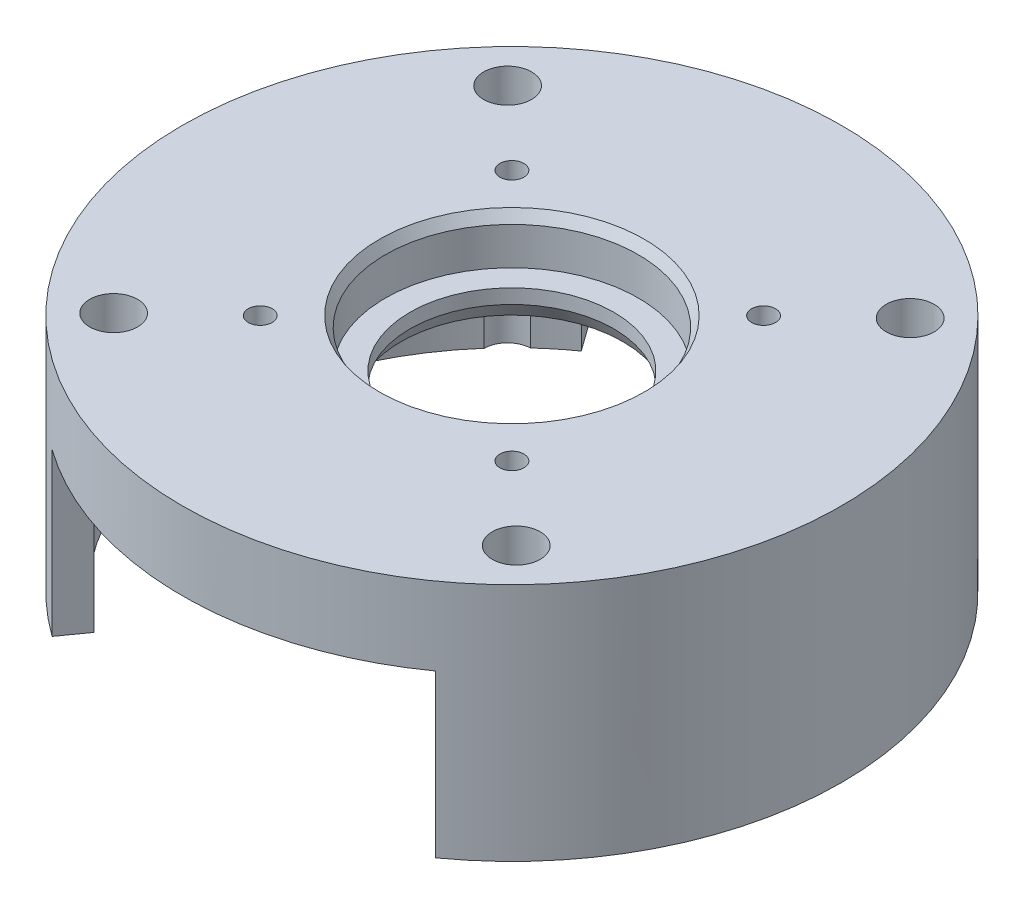
from build123d import *

# Parameters (mm, degrees)
SKETCH_1_R          = 55
EXTRUDE_1_DEPTH     = 40
SKETCH_2_R          = 50
CUT_EXTRUDE_1_DEPTH = 27
SKETCH_3_R          = 17
CUT_EXTRUDE_2_DEPTH = 14
SKETCH_4_R          = 4
CUT_EXTRUDE_3_DEPTH = 41
SKETCH1_R           = 21.1
CUT_EXTRUDE1_DEPTH  = 8
CHAMFER1_SIZE       = 1
CHAMFER1_SIZE2      = 1.732050808
SKETCH2_R           = 2
CUT_EXTRUDE2_DEPTH  = 41
CUT_EXTRUDE3_DEPTH  = 4
CUT_EXTRUDE4_DEPTH  = 27
CHAMFER2_SIZE       = 1.5
CHAMFER2_SIZE2      = 2.598076211


with BuildPart() as part:
    # Эскиз1 → Бобышка-Вытянуть1 (new body)
    with BuildSketch(Plane(origin=(0, 0, 0), x_dir=(1, 0, 0), z_dir=(0, 1, 0))):
        with Locations(Location((0, 0, 0), (0, 0, 270))):  # turned: the seam where the file's is
            Circle(SKETCH_1_R)
    extrude(amount=EXTRUDE_1_DEPTH)

    # Эскиз2 → Вырез-Вытянуть1 (cut)
    with BuildSketch(Plane.XZ):
        with Locations(Location((0, 0, 0), (0, 0, 270))):  # turned: the seam where the file's is
            Circle(SKETCH_2_R)
    extrude(amount=-CUT_EXTRUDE_1_DEPTH, mode=Mode.SUBTRACT)

    # Эскиз3 → Вырез-Вытянуть2 (cut, through all)
    with BuildSketch(Plane.XZ.offset(-27)):
        with Locations(Location((0, 0, 0), (0, 0, 270))):  # turned: the seam where the file's is
            Circle(SKETCH_3_R)
    extrude(amount=-CUT_EXTRUDE_2_DEPTH, mode=Mode.SUBTRACT)

    # Эскиз4 → Вырез-Вытянуть3 (cut, through all)
    with BuildSketch(Plane(origin=(0, 40, 0), x_dir=(1, 0, 0), z_dir=(0, 1, 0))):
        with Locations(Location((33.591727056, -32.872418125, 0), (0, 0, 270))):  # turned: the seam where the file's is
            Circle(SKETCH_4_R)
        with Locations(Location((-33.591727056, -32.872418125, 0), (0, 0, 270))):  # turned: the seam where the file's is
            Circle(SKETCH_4_R)
        with Locations(Location((-33.591727056, 32.872418125, 0), (0, 0, 270))):  # turned: the seam where the file's is
            Circle(SKETCH_4_R)
        with Locations(Location((33.591727056, 32.872418125, 0), (0, 0, 270))):  # turned: the seam where the file's is
            Circle(SKETCH_4_R)
    extrude(amount=-CUT_EXTRUDE_3_DEPTH, mode=Mode.SUBTRACT)

    # Sketch1 → Cut-Extrude1 (cut)
    with BuildSketch(Plane(origin=(0, 40, 0), x_dir=(1, 0, 0), z_dir=(0, 1, 0))):
        with Locations(Location((0, 0, 0), (0, 0, 270))):  # turned: the seam where the file's is
            Circle(SKETCH1_R)
    extrude(amount=-CUT_EXTRUDE1_DEPTH, mode=Mode.SUBTRACT)

    # Chamfer1
    chamfer1_edges = [part.edges().sort_by_distance(p)[0] for p in [
        (0, 40, -21.1),
    ]]
    chamfer1_side = [part.faces().sort_by_distance(p)[0] for p in [
        (0, 40, -53.444365081),
    ]]
    chamfer(chamfer1_edges, length=CHAMFER1_SIZE, length2=CHAMFER1_SIZE2, reference=chamfer1_side[0])

    # Sketch2 → Cut-Extrude2 (cut, through all)
    with BuildSketch(Plane(origin=(0, 40, 0), x_dir=(1, 0, 0), z_dir=(0, 1, 0))):
        with Locations(Location((21, 21, 0), (0, 0, 270))):  # turned: the seam where the file's is
            Circle(SKETCH2_R)
        with Locations(Location((-21, 21, 0), (0, 0, 270))):  # turned: the seam where the file's is
            Circle(SKETCH2_R)
        with Locations(Location((21, -21, 0), (0, 0, 270))):  # turned: the seam where the file's is
            Circle(SKETCH2_R)
        with Locations(Location((-21, -21, 0), (0, 0, 270))):  # turned: the seam where the file's is
            Circle(SKETCH2_R)
    extrude(amount=-CUT_EXTRUDE2_DEPTH, mode=Mode.SUBTRACT)

    # Sketch3 → Cut-Extrude3 (cut)
    with BuildSketch(Plane.XZ.offset(-27)):
        Polygon((-21, -16.9), (-24.550704156, -18.95), (-24.550704156, -23.05), (-21, -25.1), (-17.449295844, -23.05), (-17.449295844, -18.95), align=None)
        Polygon((-21, 25.1), (-24.550704156, 23.05), (-24.550704156, 18.95), (-21, 16.9), (-17.449295844, 18.95), (-17.449295844, 23.05), align=None)
        Polygon((24.550704156, 23.05), (21, 25.1), (17.449295844, 23.05), (17.449295844, 18.95), (21, 16.9), (24.550704156, 18.95), align=None)
        Polygon((24.550704156, -18.95), (21, -16.9), (17.449295844, -18.95), (17.449295844, -23.05), (21, -25.1), (24.550704156, -23.05), align=None)
    extrude(amount=-CUT_EXTRUDE3_DEPTH, mode=Mode.SUBTRACT)

    # Sketch4 → Cut-Extrude4 (cut)
    with BuildSketch(Plane.XZ):
        with BuildLine():
            Line((32, -44.732538493), (29.090909091, -40.665944084))
            ThreePointArc((29.090909091, -40.665944084), (0, -50), (-29.090909091, -40.665944084))
            Line((-29.090909091, -40.665944084), (-32, -44.732538493))
            ThreePointArc((-32, -44.732538493), (0, -55), (32, -44.732538493))
        make_face()
        with BuildLine():
            Line((32, 44.732538493), (29.090909091, 40.665944084))
            ThreePointArc((29.090909091, 40.665944084), (0, 50), (-29.090909091, 40.665944084))
            Line((-29.090909091, 40.665944084), (-32, 44.732538493))
            ThreePointArc((-32, 44.732538493), (0, 55), (32, 44.732538493))
        make_face()
    extrude(amount=-CUT_EXTRUDE4_DEPTH, mode=Mode.SUBTRACT)

    # Chamfer2
    chamfer2_edges = [part.edges().sort_by_distance(p)[0] for p in [
        (0, 27, 17),
    ]]
    chamfer2_side = [part.faces().sort_by_distance(p)[0] for p in [
        (29.336369105, 27, 43.564176197),
    ]]
    chamfer(chamfer2_edges, length=CHAMFER2_SIZE, length2=CHAMFER2_SIZE2, reference=chamfer2_side[0])


solid = part.part
